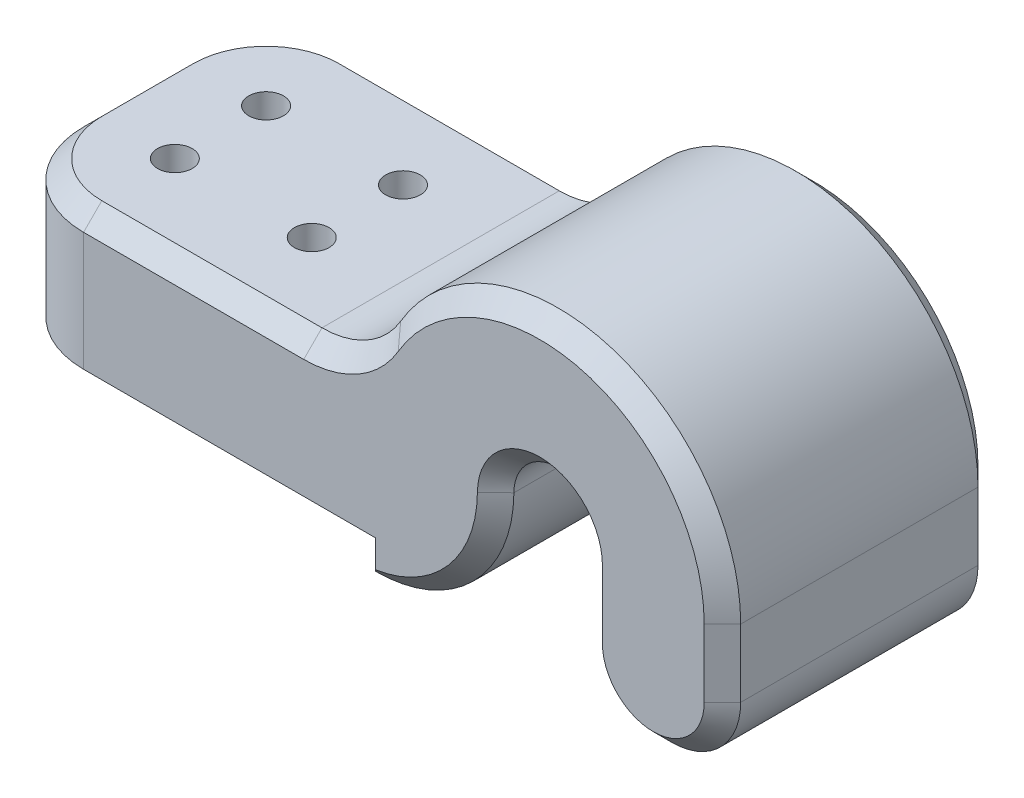
from build123d import *

# Parameters (mm, degrees)
BOSS_EXTRUDE1_DEPTH   = 30
FILLET1_R             = 10
CHAMFER1_SIZE         = 2
SKETCH3_R             = 1.9
CUT_EXTRUDE1_DEPTH    = 32.825
CHAMFER2_SIZE         = 2
CHAMFER2_SIZE2        = 0.352653961
CHAMFER2_PART_2_SIZE  = 2
CHAMFER2_PART_2_SIZE2 = 0.352653961
CHAMFER2_PART_3_SIZE  = 2
CHAMFER2_PART_3_SIZE2 = 0.352653961
CHAMFER2_PART_4_SIZE  = 2
CHAMFER2_PART_4_SIZE2 = 0.352653961


with BuildPart() as part:
    # Sketch1 → Boss-Extrude1 (new body)
    with BuildSketch(Plane.XY):
        with BuildLine():
            Line((0, 3.175), (0, 0))
            ThreePointArc((0, 0), (10.672667654, 4.397249215), (15.150137433, 15.036511402))
            ThreePointArc((15.150137433, 15.036511402), (20.018255831, 19.849965642), (24.85, 15))
            Line((24.85, 15), (24.85, 7.575))
            ThreePointArc((24.85, 7.575), (32.425, 0), (40, 7.575))
            Line((40, 7.575), (40, 15))
            ThreePointArc((40, 15), (25.241541186, 34.300938992), (2.747375401, 25.116666667))
            ThreePointArc((2.747375401, 25.116666667), (-0.908189135, 21.497922919), (-5.878936899, 20.175))
            Line((-5.878936899, 20.175), (-40, 20.175))
            Line((-40, 20.175), (-40, 3.175))
            Line((-40, 3.175), (0, 3.175))
        make_face()
    extrude(amount=BOSS_EXTRUDE1_DEPTH)

    # Fillet1
    fillet1_edges = [part.edges().sort_by_distance(p)[0] for p in [
        (-40, 11.675, 0),
        (-40, 11.675, 30),
    ]]
    fillet(fillet1_edges, radius=FILLET1_R)

    # Chamfer1
    chamfer1_edges = [part.edges().sort_by_distance(p)[0] for p in [
        (-17.939468449, 20.175, 0),
        (-0.908189135, 21.497922919, 0),
        (25.241541186, 34.300938992, 0),
        (40, 11.2875, 0),
        (10.672667654, 4.397249215, 30),
        (32.425, 0, 0),
        (24.85, 11.2875, 0),
        (20.018255831, 19.849965642, 0),
        (10.672667654, 4.397249215, 0),
        (0, 1.5875, 0),
        (20.018255831, 19.849965642, 30),
        (24.85, 11.2875, 30),
        (32.425, 0, 30),
        (40, 11.2875, 30),
        (25.241541186, 34.300938992, 30),
        (-40, 3.175, 15),
        (-40, 20.175, 15),
        (-15, 3.175, 0),
        (-15, 3.175, 30),
        (-37.071067812, 3.175, 27.071067812),
        (-0.908189135, 21.497922919, 30),
        (-37.071067812, 3.175, 2.928932188),
        (-37.071067812, 20.175, 27.071067812),
        (-37.071067812, 20.175, 2.928932188),
        (-17.939468449, 20.175, 30),
        (0, 1.5875, 30),
    ]]
    chamfer(chamfer1_edges, length=CHAMFER1_SIZE)

    # Sketch3 → Cut-Extrude1 (cut, through all)
    with BuildSketch(Plane.XZ.offset(-3.175)):
        with Locations((-30, 20)):
            Circle(SKETCH3_R)
        with Locations((-15, 20)):
            Circle(SKETCH3_R)
        with Locations((-15, 10)):
            Circle(SKETCH3_R)
        with Locations((-30, 10)):
            Circle(SKETCH3_R)
    extrude(amount=-CUT_EXTRUDE1_DEPTH, mode=Mode.SUBTRACT)

    # Chamfer2
    chamfer2_edges = [part.edges().sort_by_distance(p)[0] for p in [
        (-31.9, 3.175, 10),
    ]]
    chamfer2_side = [part.faces().sort_by_distance(p)[0] for p in [
        (-31.9, 11.675, 10),
    ]]
    chamfer(chamfer2_edges, length=CHAMFER2_SIZE, length2=CHAMFER2_SIZE2, reference=chamfer2_side[0])

    # Chamfer2 part 2
    chamfer2_part_2_edges = [part.edges().sort_by_distance(p)[0] for p in [
        (-16.9, 3.175, 10),
    ]]
    chamfer2_part_2_side = [part.faces().sort_by_distance(p)[0] for p in [
        (-16.9, 11.675, 10),
    ]]
    chamfer(chamfer2_part_2_edges, length=CHAMFER2_PART_2_SIZE, length2=CHAMFER2_PART_2_SIZE2, reference=chamfer2_part_2_side[0])

    # Chamfer2 part 3
    chamfer2_part_3_edges = [part.edges().sort_by_distance(p)[0] for p in [
        (-16.9, 3.175, 20),
    ]]
    chamfer2_part_3_side = [part.faces().sort_by_distance(p)[0] for p in [
        (-16.9, 11.675, 20),
    ]]
    chamfer(chamfer2_part_3_edges, length=CHAMFER2_PART_3_SIZE, length2=CHAMFER2_PART_3_SIZE2, reference=chamfer2_part_3_side[0])

    # Chamfer2 part 4
    chamfer2_part_4_edges = [part.edges().sort_by_distance(p)[0] for p in [
        (-31.9, 3.175, 20),
    ]]
    chamfer2_part_4_side = [part.faces().sort_by_distance(p)[0] for p in [
        (-31.9, 11.675, 20),
    ]]
    chamfer(chamfer2_part_4_edges, length=CHAMFER2_PART_4_SIZE, length2=CHAMFER2_PART_4_SIZE2, reference=chamfer2_part_4_side[0])


solid = part.part
